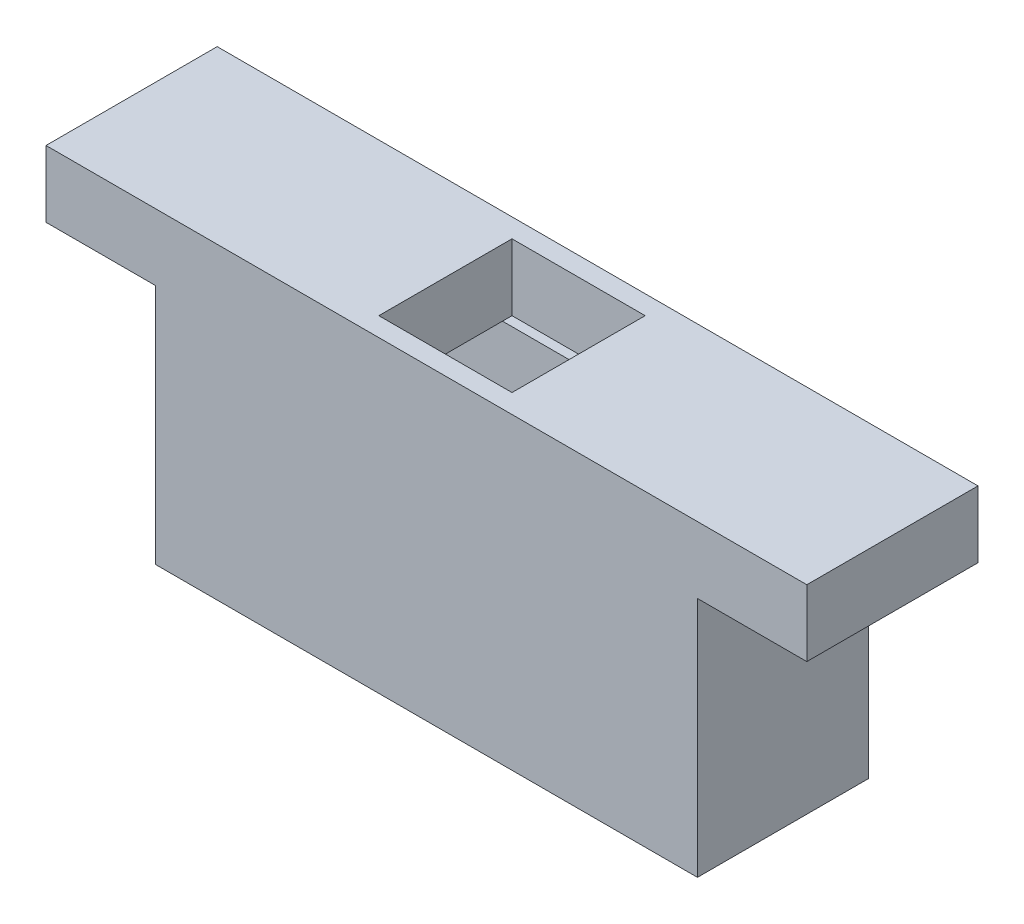
from build123d import *

# Parameters (mm, degrees)
BOSS_EXTRUDE2_DEPTH = 18
SKETCH4_W           = 53
SKETCH4_H           = 12
CUT_EXTRUDE2_DEPTH  = 25.4
SKETCH5_W           = 14
SKETCH5_H           = 14
CUT_EXTRUDE3_DEPTH  = 7


with BuildPart() as part:
    # Sketch3 → Boss-Extrude2 (new body)
    with BuildSketch(Plane.XY):
        Polygon((0, 0), (0, 25.4), (-11.5, 25.4), (-11.5, 32.4), (68.5, 32.4), (68.5, 25.4), (57, 25.4), (57, 0), align=None)
    extrude(amount=BOSS_EXTRUDE2_DEPTH)

    # Sketch4 → Cut-Extrude2 (cut)
    with BuildSketch(Plane.XZ):
        with Locations((28.5, 9)):
            Rectangle(SKETCH4_W, SKETCH4_H)
    extrude(amount=-CUT_EXTRUDE2_DEPTH, mode=Mode.SUBTRACT)

    # Sketch5 → Cut-Extrude3 (cut)
    with BuildSketch(Plane(origin=(0, 32.4, 0), x_dir=(1, 0, 0), z_dir=(0, 1, 0))):
        with Locations((28.5, -9)):
            Rectangle(SKETCH5_W, SKETCH5_H)
    extrude(amount=-CUT_EXTRUDE3_DEPTH, mode=Mode.SUBTRACT)


solid = part.part
